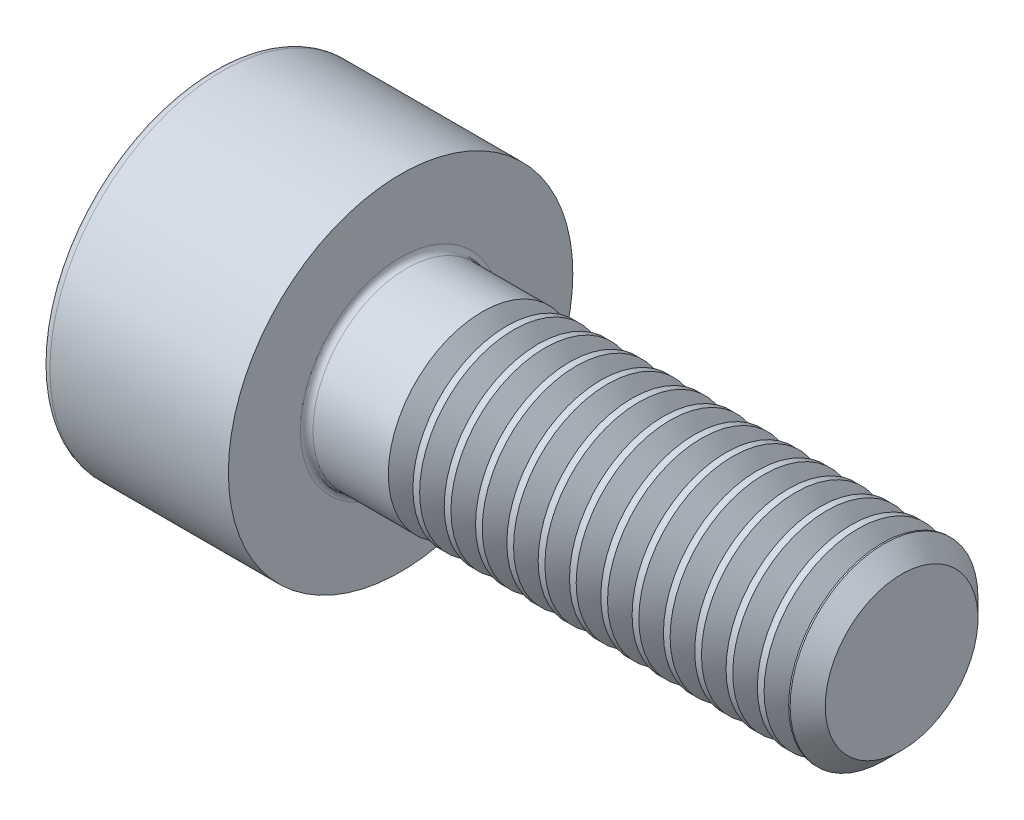
from build123d import *

# Parameters (mm, degrees)
FILLET1_R       = 0.1
FILLET2_R       = 0.15
HEX_2_DEPTH     = 1.3
THDSCHPAT_COUNT = 13
THDSCHPAT_PITCH = 0.5


with BuildPart() as part:
    # BodySke → Base-Revolve (revolve)
    with BuildSketch(Plane.XY):
        Polygon((0, 0), (0, 2.75), (3, 2.75), (3, 1.5), (10.7195, 1.5), (11, 1.2195), (11, 0), align=None)
    revolve(axis=Axis((-31.75, 0, 0), (1, 0, 0)))

    # Fillet1
    fillet1_edges = [part.edges().sort_by_distance(p)[0] for p in [
        (3, -1.5, 0),
    ]]
    fillet(fillet1_edges, radius=FILLET1_R)

    # Fillet2
    fillet2_edges = [part.edges().sort_by_distance(p)[0] for p in [
        (0, -2.75, 0),
    ]]
    fillet(fillet2_edges, radius=FILLET2_R)

    # Sketch2 → Hex-PreBroach (revolve, cut)
    with BuildSketch(Plane.XY):
        Polygon((0, 1.28), (1.3, 1.28), (2.039008345, 0), (0, 0), align=None)
    revolve(axis=Axis((0, 0, 0), (1, 0, 0)), mode=Mode.SUBTRACT)

    # Sketch3 → Hex 2 (cut)
    with BuildSketch(Plane(origin=(0, 0, 0), x_dir=(0, 0.5, 0.866025404), z_dir=(-1, 0, 0))):
        Polygon((0.739008345, 1.28), (-0.739008345, 1.28), (-1.478016689, 0), (-0.739008345, -1.28), (0.739008345, -1.28), (1.478016689, 0), align=None)
    extrude(amount=-HEX_2_DEPTH, mode=Mode.SUBTRACT)

    # ThdSchSke → ThreadSchematic (revolve, cut)
    with BuildSketch(Plane.XY):
        Polygon((4.5, -1.2195), (4.303591786, -1.5), (4.303591786, -1.875), (4.696408214, -1.875), (4.696408214, -1.5), align=None)
    threadschematic = revolve(axis=Axis((-3.175, 0, 0), (1, 0, 0)), mode=Mode.SUBTRACT)

    # ThdSchPat: ThreadSchematic ×13
    with Locations(*[(i * THDSCHPAT_PITCH, 0, 0) for i in range(1, THDSCHPAT_COUNT)]):
        add(threadschematic, mode=Mode.SUBTRACT)


solid = part.part
